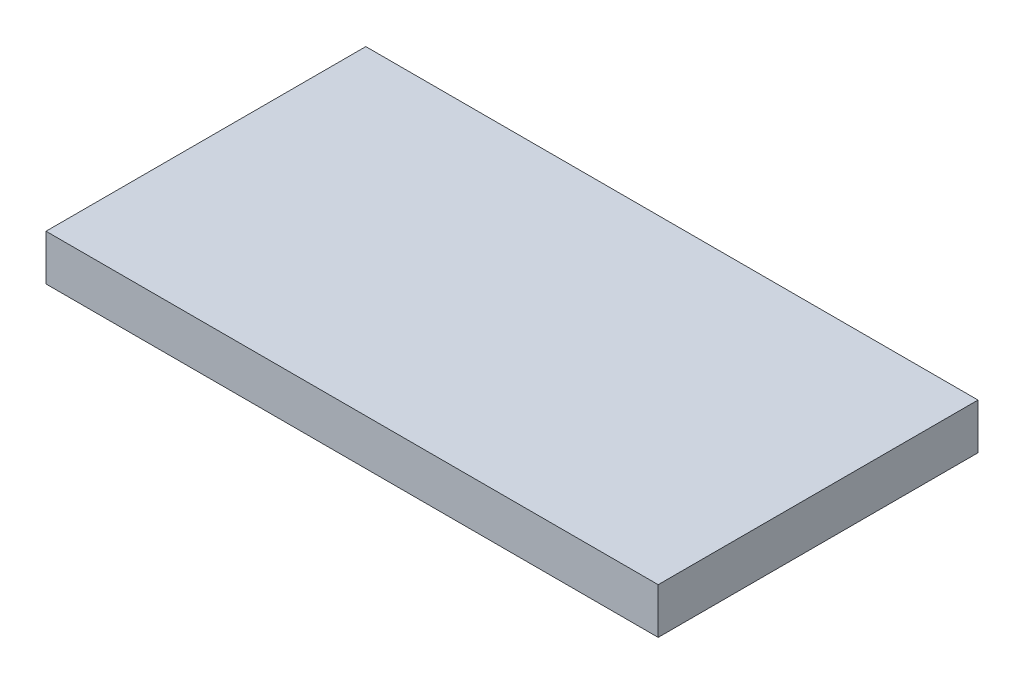
from build123d import *

# Parameters (mm, degrees)
CROQUIS1_W              = 134
CROQUIS1_H              = 70
SALIENTE_EXTRUIR1_DEPTH = 10


with BuildPart() as part:
    # Croquis1 → Saliente-Extruir1 (new body)
    with BuildSketch(Plane(origin=(0, 0, 0), x_dir=(1, 0, 0), z_dir=(0, 1, 0))):
        with Locations((67, 35)):
            Rectangle(CROQUIS1_W, CROQUIS1_H)
    extrude(amount=SALIENTE_EXTRUIR1_DEPTH)


solid = part.part
